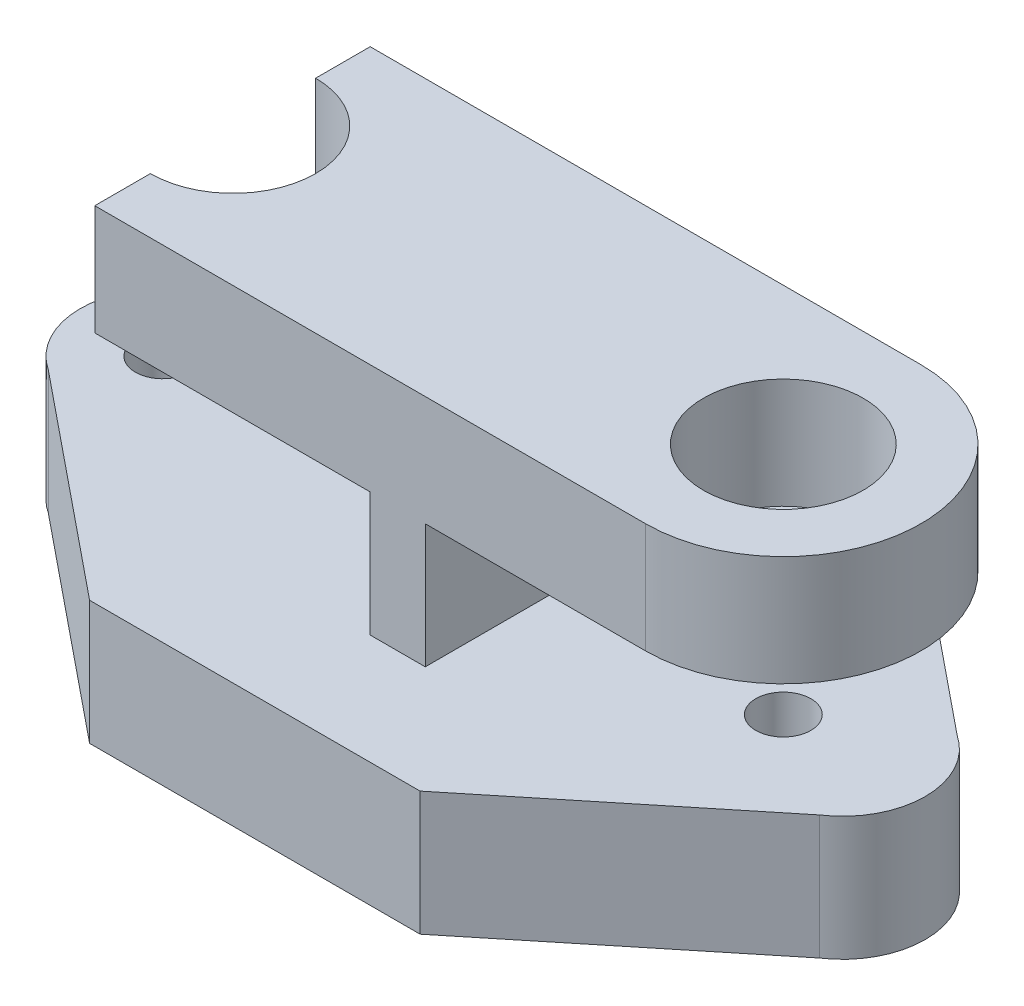
from build123d import *

# Parameters (mm, degrees)
SKETCH1_R               = 0.5
BOSS_EXTRUDE1_DEPTH     = 2.25
CUT_EXTRUDE3_DEPTH      = 1
CUT_EXTRUDE4_DEPTH      = 1.25
BOSS_EXTRUDE2_DEPTH     = 2.25
SKETCH7_R               = 1
BOSS_EXTRUDE3_DEPTH     = 2
SKETCH8_R               = 0.5
CUT_EXTRUDE5_DEPTH      = 3
M3_5_TAPPED_HOLE1_D     = 2.9
M3_5_TAPPED_HOLE1_DEPTH = 2
M3_5_TAPPED_HOLE1_TIP   = 0.871247898


with BuildPart() as part:
    # Sketch1 → Boss-Extrude1 (new body)
    with BuildSketch(Plane(origin=(0, 0, -0.343889451), x_dir=(1, 0, 0), z_dir=(0, 1, 0))):
        with BuildLine():
            Line((0, -0.009375659), (6, -0.009375659))
            Line((6, -0.009375659), (10, -3.259375659))
            ThreePointArc((10, -3.259375659), (10.670843802, -4.509375659), (10, -5.759375659))
            Line((10, -5.759375659), (6, -9.009375659))
            Line((6, -9.009375659), (0, -9.009375659))
            Line((0, -9.009375659), (-4, -5.759375659))
            ThreePointArc((-4, -5.759375659), (-4.670843802, -4.509375659), (-4, -3.259375659))
            Line((-4, -3.259375659), (0, -0.009375659))
        make_face()
        with Locations((-3.170843802, -4.509375659)):
            Circle(SKETCH1_R, mode=Mode.SUBTRACT)
    extrude(amount=BOSS_EXTRUDE1_DEPTH)

    # Sketch4 → Cut-Extrude3 (cut)
    with BuildSketch(Plane.XZ):
        with BuildLine():
            Line((-4.288877791, 5.165486209), (-0.670843802, 5.165486209))
            Line((-0.670843802, 5.165486209), (-0.670843802, 3.165486209))
            Line((-0.670843802, 3.165486209), (-4.288877791, 3.165486209))
            ThreePointArc((-4.288877791, 3.165486209), (-4.670843802, 4.165486209), (-4.288877791, 5.165486209))
        make_face()
    extrude(amount=-CUT_EXTRUDE3_DEPTH, mode=Mode.SUBTRACT)

    # Sketch5 → Cut-Extrude4 (cut)
    with BuildSketch(Plane(origin=(0, 0, 0), x_dir=(-1, 0, 0), z_dir=(0, -1, 0))):
        with BuildLine():
            Line((0.170843802, -7.665486209), (-6.170843802, -7.665486209))
            ThreePointArc((-6.170843802, -7.665486209), (-6.524397193, -7.519039599), (-6.670843802, -7.165486209))
            Line((-6.670843802, -7.165486209), (-6.670843802, -1.165486209))
            ThreePointArc((-6.670843802, -1.165486209), (-6.524397193, -0.811932818), (-6.170843802, -0.665486209))
            Line((-6.170843802, -0.665486209), (0.170843802, -0.665486209))
            ThreePointArc((0.170843802, -0.665486209), (0.524397193, -0.811932818), (0.670843802, -1.165486209))
            Line((0.670843802, -1.165486209), (0.670843802, -7.165486209))
            ThreePointArc((0.670843802, -7.165486209), (0.524397193, -7.519039599), (0.170843802, -7.665486209))
        make_face()
    extrude(amount=-CUT_EXTRUDE4_DEPTH, mode=Mode.SUBTRACT)

    # Sketch6 → Boss-Extrude2 (add)
    with BuildSketch(Plane(origin=(0, 2.25, 0), x_dir=(1, 0, 0), z_dir=(0, 1, 0))):
        Polygon((0.593843358, -3.915486209), (3.093843358, -3.915486209), (3.093843358, -1.665486209), (4.093843358, -1.665486209), (4.093843358, -6.665486209), (3.093843358, -6.665486209), (3.093843358, -4.415486209), (0.593843358, -4.415486209), align=None)
    extrude(amount=BOSS_EXTRUDE2_DEPTH)

    # Sketch7 → Boss-Extrude3 (add)
    with BuildSketch(Plane(origin=(0, 4.5, 0), x_dir=(1, 0, 0), z_dir=(0, 1, 0))):
        with BuildLine():
            Line((-1.906156642, -1.665486209), (-1.906156642, -2.656110549))
            ThreePointArc((-1.906156642, -2.656110549), (-0.406156642, -4.156110549), (-1.906156642, -5.656110549))
            Line((-1.906156642, -5.656110549), (-1.906156642, -6.665486209))
            Line((-1.906156642, -6.665486209), (8.093843358, -6.665486209))
            ThreePointArc((8.093843358, -6.665486209), (10.593843358, -4.165486209), (8.093843358, -1.665486209))
            Line((8.093843358, -1.665486209), (-1.906156642, -1.665486209))
        make_face()
        with Locations((8.093843358, -4.165486209)):
            Circle(SKETCH7_R, mode=Mode.SUBTRACT)
    extrude(amount=BOSS_EXTRUDE3_DEPTH)

    # Sketch8 → Cut-Extrude5 (cut)
    with BuildSketch(Plane(origin=(0, 2.25, 0), x_dir=(1, 0, 0), z_dir=(0, 1, 0))):
        with Locations((8.093843358, -4.165486209)):
            Circle(SKETCH8_R)
    extrude(amount=-CUT_EXTRUDE5_DEPTH, mode=Mode.SUBTRACT)

    # M3.5 Tapped Hole1
    with Locations(Plane(origin=(8.093843358, 6.5, 4.165486209), x_dir=(0, 0, 1), z_dir=(0, 1, 0))):
        with Locations((0, 0)):
            Hole(M3_5_TAPPED_HOLE1_D / 2, depth=M3_5_TAPPED_HOLE1_DEPTH)
            with Locations((0, 0, -(M3_5_TAPPED_HOLE1_DEPTH + M3_5_TAPPED_HOLE1_TIP / 2))):  # 118° drill point
                Cone(0, M3_5_TAPPED_HOLE1_D / 2, M3_5_TAPPED_HOLE1_TIP, mode=Mode.SUBTRACT)


solid = part.part
